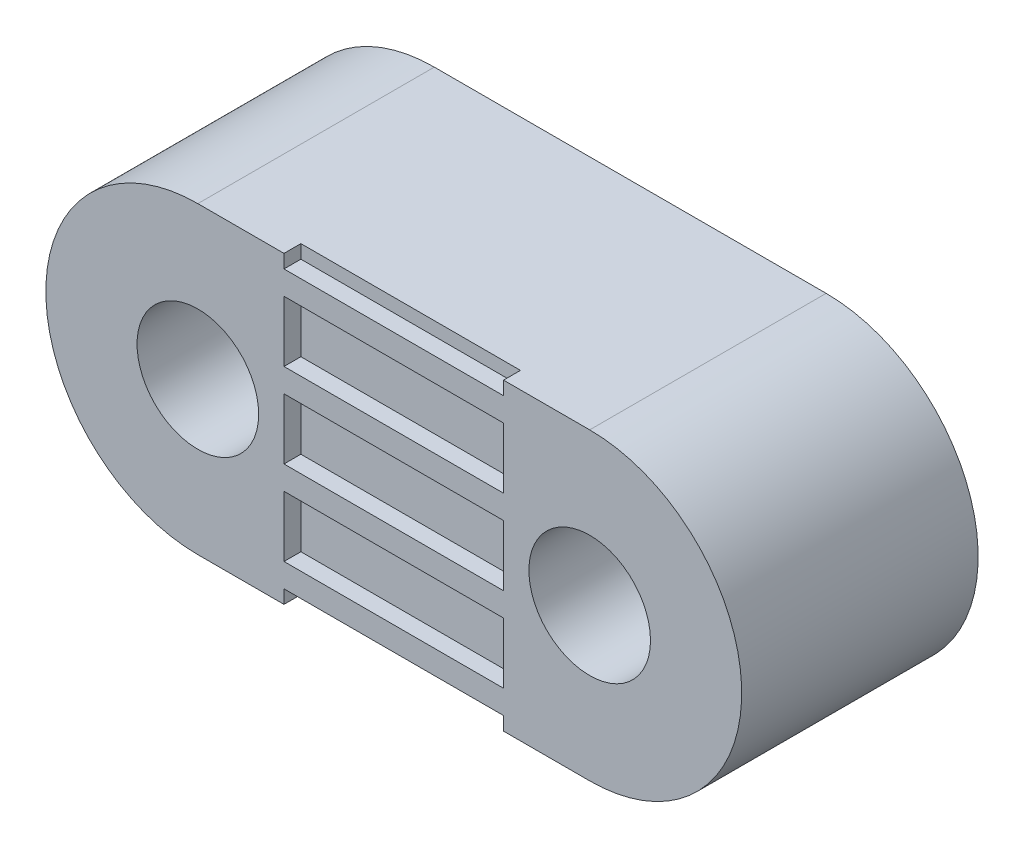
from build123d import *

# Parameters (mm, degrees)
BOSS_EXTRUDE1_DEPTH = 7
SKETCH5_R           = 1.799999865
SKETCH5_R_2         = 1.8
CUT_EXTRUDE4_DEPTH  = 8
SKETCH2_W           = 6.5
SKETCH2_H           = 1.8
SKETCH2_H_2         = 0.9
CUT_EXTRUDE1_DEPTH  = 0.5


with BuildPart() as part:
    # Sketch1 → Boss-Extrude1 (new body)
    with BuildSketch(Plane.XY):
        with BuildLine():
            Line((9, 4), (-2.6, 4))
            ThreePointArc((-2.6, 4), (-7.1, -0.5), (-2.6, -5))
            Line((-2.6, -5), (9, -5))
            ThreePointArc((9, -5), (13.5, -0.5), (9, 4))
        make_face()
    extrude(amount=-BOSS_EXTRUDE1_DEPTH)

    # Sketch5 → Cut-Extrude4 (cut, through all)
    with BuildSketch(Plane.XY):
        with Locations((9, -0.5)):
            Circle(SKETCH5_R)
        with Locations((-2.6, -0.5)):
            Circle(SKETCH5_R_2)
    extrude(amount=-CUT_EXTRUDE4_DEPTH, mode=Mode.SUBTRACT)

    # Sketch2 → Cut-Extrude1 (cut)
    with BuildSketch(Plane.XY):
        with Locations((3.200000135, 2)):
            Rectangle(SKETCH2_W, SKETCH2_H)
        with Locations((3.200000135, -5.05)):
            Rectangle(SKETCH2_W, SKETCH2_H_2)
        with Locations((3.200000135, -0.5)):
            Rectangle(SKETCH2_W, SKETCH2_H)
        with Locations((3.200000135, -3)):
            Rectangle(SKETCH2_W, SKETCH2_H)
        with Locations((3.200000135, 4.05)):
            Rectangle(SKETCH2_W, SKETCH2_H_2)
    extrude(amount=-CUT_EXTRUDE1_DEPTH, mode=Mode.SUBTRACT)


solid = part.part
